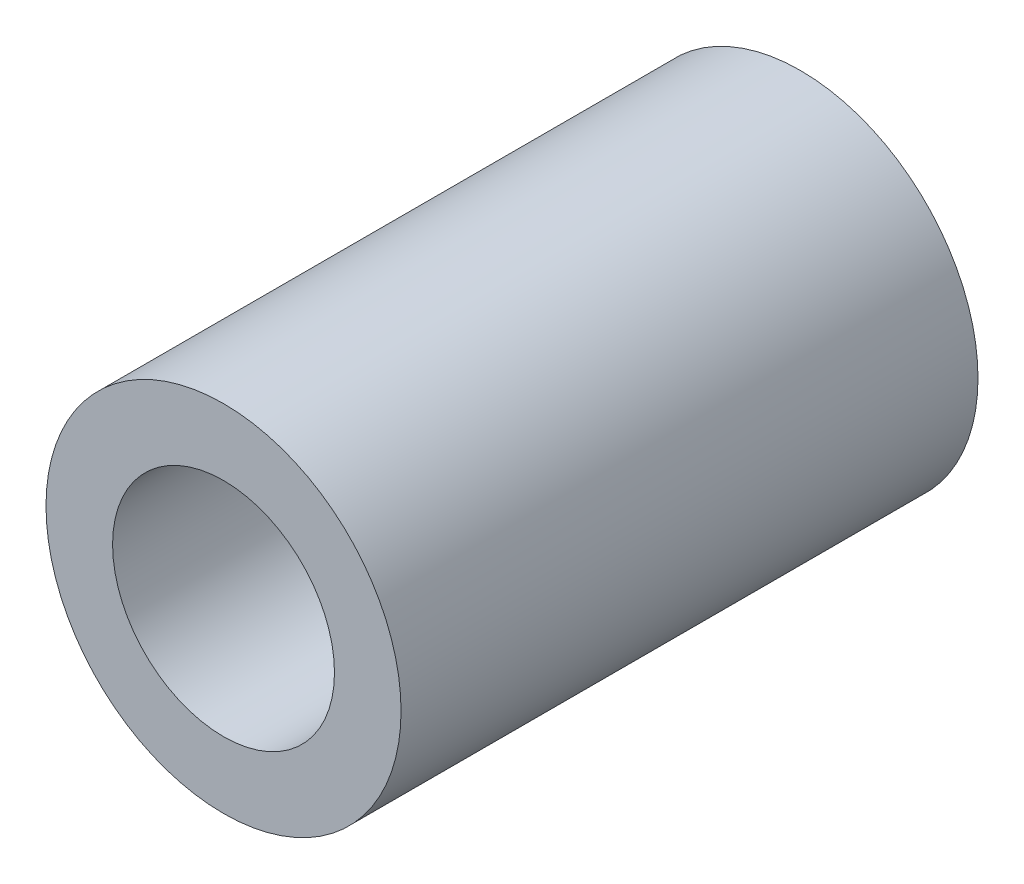
from build123d import *

# Parameters (mm, degrees)
SCHIZZO1_R                   = 4
SCHIZZO1_R_2                 = 2.5
ESTRUSIONE_ESTRUSIONE1_DEPTH = 13


with BuildPart() as part:
    # Schizzo1 → Estrusione-Estrusione1 (new body)
    with BuildSketch(Plane.XY):
        Circle(SCHIZZO1_R)
        Circle(SCHIZZO1_R_2, mode=Mode.SUBTRACT)
    extrude(amount=-ESTRUSIONE_ESTRUSIONE1_DEPTH)


solid = part.part
